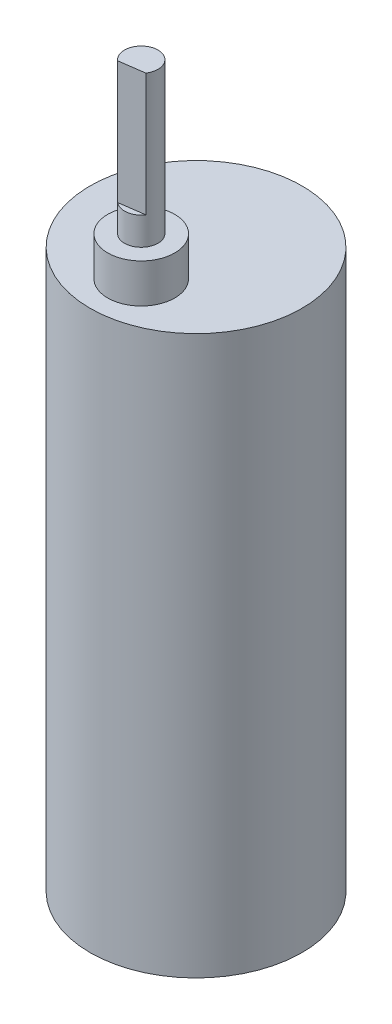
from build123d import *

# Parameters (mm, degrees)
SKETCH1_R           = 19
BOSS_EXTRUDE1_DEPTH = 100
SKETCH2_R           = 6
BOSS_EXTRUDE2_DEPTH = 7
SKETCH3_R           = 3
BOSS_EXTRUDE3_DEPTH = 27
CUT_EXTRUDE1_DEPTH  = 22


with BuildPart() as part:
    # Sketch1 → Boss-Extrude1 (new body)
    with BuildSketch(Plane(origin=(0, 0, 0), x_dir=(1, 0, 0), z_dir=(0, 1, 0))):
        Circle(SKETCH1_R)
    extrude(amount=BOSS_EXTRUDE1_DEPTH)

    # Sketch2 → Boss-Extrude2 (add)
    with BuildSketch(Plane(origin=(0, 100, 0), x_dir=(1, 0, 0), z_dir=(0, 1, 0))):
        with Locations((0, -9.825)):
            Circle(SKETCH2_R)
    extrude(amount=BOSS_EXTRUDE2_DEPTH)

    # Sketch3 → Boss-Extrude3 (add)
    with BuildSketch(Plane(origin=(0, 107, 0), x_dir=(1, 0, 0), z_dir=(0, 1, 0))):
        with Locations((0, -9.825)):
            Circle(SKETCH3_R)
    extrude(amount=BOSS_EXTRUDE3_DEPTH)

    # Sketch4 → Cut-Extrude1 (cut)
    with BuildSketch(Plane(origin=(0, 134, 0), x_dir=(1, 0, 0), z_dir=(0, 1, 0))):
        Polygon((-9.150633985, -13.135072473), (10.849366015, -10.314966588), (10.988990103, -11.30517117), (-9.011009897, -14.125277054), align=None)
    extrude(amount=-CUT_EXTRUDE1_DEPTH, mode=Mode.SUBTRACT)


solid = part.part
